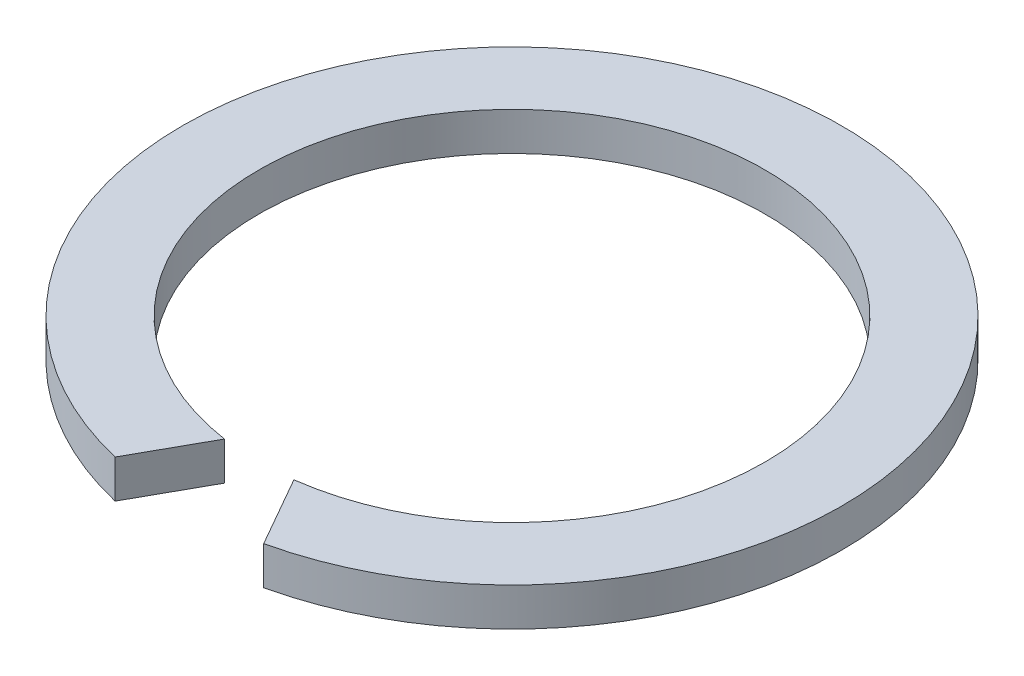
from build123d import *

# Parameters (mm, degrees)
SKETCH1_R               = 21.55
SKETCH1_R_2             = 16.55
BOSS_EXTRUDE1_DEPTH     = 2.5
CUT_EXTRUDE2_DEPTH      = 15
CUT_EXTRUDE2_DEPTH_BACK = 12


with BuildPart() as part:
    # Sketch1 → Boss-Extrude1 (new body)
    with BuildSketch(Plane(origin=(0, 0, 0), x_dir=(1, 0, 0), z_dir=(0, 1, 0))):
        Circle(SKETCH1_R)
        Circle(SKETCH1_R_2, mode=Mode.SUBTRACT)
    extrude(amount=BOSS_EXTRUDE1_DEPTH)

    # Sketch3 → Cut-Extrude2 (cut, two sides)
    with BuildSketch(Plane(origin=(0, 0, 0), x_dir=(1, 0, 0), z_dir=(0, 1, 0))) as cut_extrude2_sk:
        Polygon((-6.052029067, -22.881380435), (5.842839776, -22.881380435), (1.707646095, -15.637661849), (0, -15.637661849), (-2.025097964, -15.637661849), align=None)
    extrude(amount=CUT_EXTRUDE2_DEPTH, mode=Mode.SUBTRACT)
    extrude(cut_extrude2_sk.sketch, amount=-CUT_EXTRUDE2_DEPTH_BACK, mode=Mode.SUBTRACT)


solid = part.part
